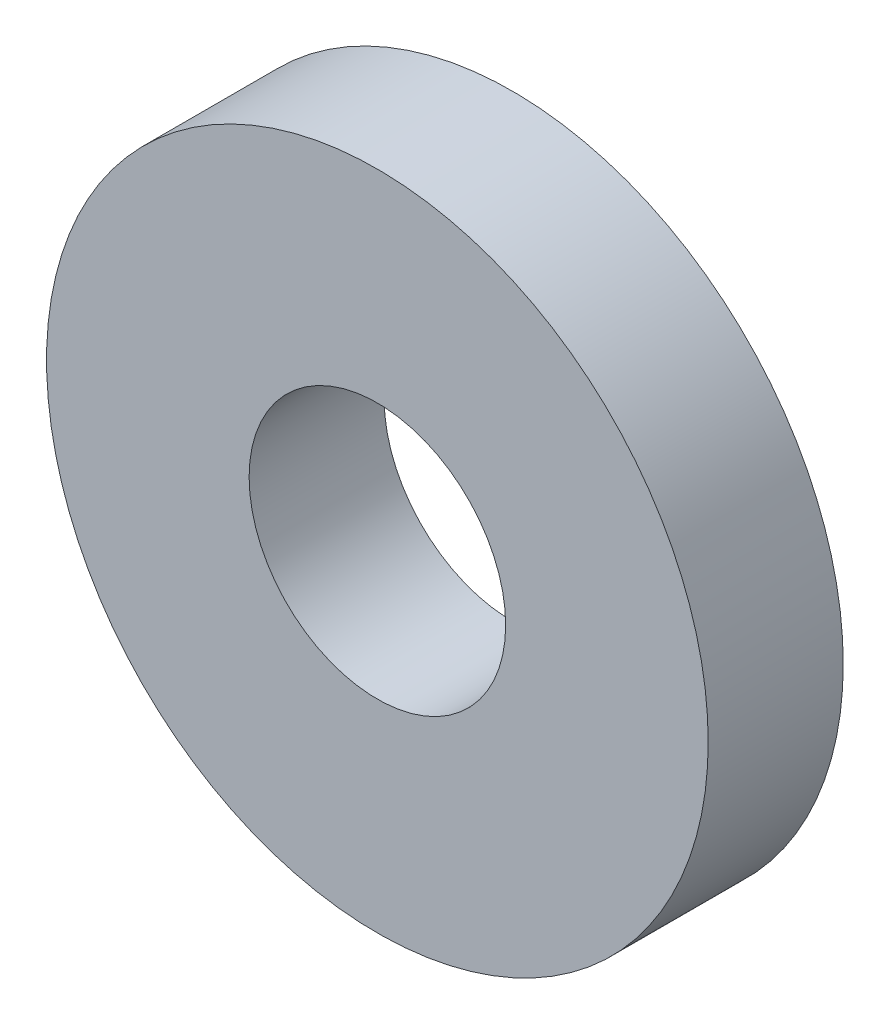
from build123d import *

# Parameters (mm, degrees)
SKETCH1_R           = 2.45
SKETCH1_R_2         = 0.95
BOSS_EXTRUDE1_DEPTH = 1


with BuildPart() as part:
    # Sketch1 → Boss-Extrude1 (new body)
    with BuildSketch(Plane.XY):
        Circle(SKETCH1_R)
        Circle(SKETCH1_R_2, mode=Mode.SUBTRACT)
    extrude(amount=BOSS_EXTRUDE1_DEPTH)


solid = part.part
